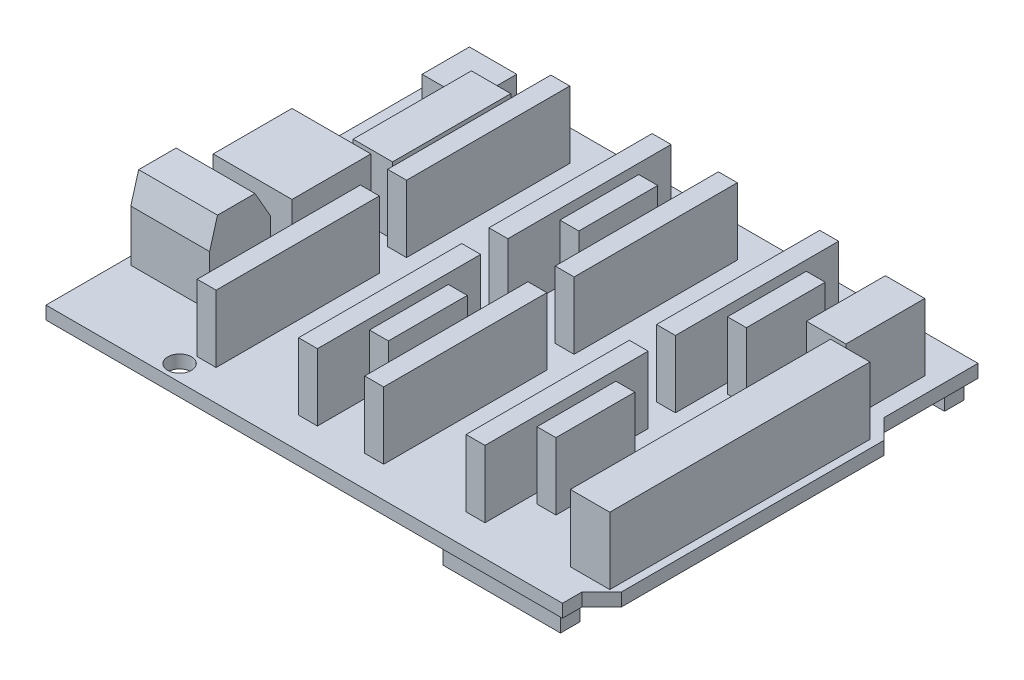
from build123d import *

# Parameters (mm, degrees)
SKETCH1_R           = 1.5
BOSS_EXTRUDE1_DEPTH = 1.65
SKETCH2_W           = 14.9
SKETCH2_H           = 2.5
SKETCH2_W_2         = 4.5
SKETCH2_W_3         = 9.5
BOSS_EXTRUDE2_DEPTH = 2.5
SKETCH3_W           = 5
SKETCH3_H           = 15
SKETCH3_W_2         = 10
SKETCH3_H_2         = 10
SKETCH3_W_3         = 2.4
SKETCH3_H_3         = 20.7
SKETCH3_H_4         = 33
BOSS_EXTRUDE3_DEPTH = 8.5
SKETCH4_W           = 10
SKETCH4_H           = 7.75
BOSS_EXTRUDE4_DEPTH = 10
CUT_EXTRUDE1_DEPTH  = 10
SKETCH6_W           = 6
SKETCH6_H           = 6
BOSS_EXTRUDE5_DEPTH = 3.5


with BuildPart() as part:
    # Sketch1 → Boss-Extrude1 (new body)
    with BuildSketch(Plane(origin=(0, 0, 0), x_dir=(1, 0, 0), z_dir=(0, 1, 0))):
        Polygon((68, 5), (65.5, 2.5), (65.5, 0), (0, 0), (0, 52.7), (65.5, 52.7), (65.5, 40.75), (68, 38.25), align=None)
        with Locations((13.75, 50.4)):
            Circle(SKETCH1_R, mode=Mode.SUBTRACT)
        with Locations((14.9, 2.04)):
            Circle(SKETCH1_R, mode=Mode.SUBTRACT)
    extrude(amount=BOSS_EXTRUDE1_DEPTH)

    # Sketch2 → Boss-Extrude2 (add)
    with BuildSketch(Plane(origin=(0, 0, 0), x_dir=(-1, 0, 0), z_dir=(0, -1, 0))):
        with Locations((-57.05, 2)):
            Rectangle(SKETCH2_W, SKETCH2_H)
        with Locations((-62.25, 50.7)):
            Rectangle(SKETCH2_W_2, SKETCH2_H)
        with Locations((-27.25, 50.7)):
            Rectangle(SKETCH2_W_3, SKETCH2_H)
    extrude(amount=BOSS_EXTRUDE2_DEPTH)

    # Sketch3 → Boss-Extrude3 (add)
    with BuildSketch(Plane(origin=(0, 1.65, 0), x_dir=(1, 0, 0), z_dir=(0, 1, 0))):
        with Locations((12.25, 36.7)):
            Rectangle(SKETCH3_W, SKETCH3_H)
        with Locations((7.5, 23.7)):
            Rectangle(SKETCH3_W_2, SKETCH3_H_2)
        with Locations((16.45, 14.275)):
            Rectangle(SKETCH3_W_3, SKETCH3_H_3)
        with Locations((29.3, 14.275)):
            Rectangle(SKETCH3_W_3, SKETCH3_H_3)
        with Locations((37.7, 14.275)):
            Rectangle(SKETCH3_W_3, SKETCH3_H_3)
        with Locations((50.55, 14.275)):
            Rectangle(SKETCH3_W_3, SKETCH3_H_3)
        with Locations((16.45, 38.425)):
            Rectangle(SKETCH3_W_3, SKETCH3_H_3)
        with Locations((29.3, 38.425)):
            Rectangle(SKETCH3_W_3, SKETCH3_H_3)
        with Locations((37.7, 38.425)):
            Rectangle(SKETCH3_W_3, SKETCH3_H_3)
        with Locations((50.55, 38.425)):
            Rectangle(SKETCH3_W_3, SKETCH3_H_3)
        with Locations((61, 42.95)):
            Rectangle(SKETCH3_W, SKETCH3_H_2)
        with Locations((64.5, 21)):
            Rectangle(SKETCH3_W, SKETCH3_H_4)
        with Locations((32.95, 14.275)):
            Rectangle(SKETCH3_W_3, SKETCH3_H_2)
        with Locations((32.95, 38.425)):
            Rectangle(SKETCH3_W_3, SKETCH3_H_2)
        with Locations((54.2, 38.425)):
            Rectangle(SKETCH3_W_3, SKETCH3_H_2)
        with Locations((54.2, 14.275)):
            Rectangle(SKETCH3_W_3, SKETCH3_H_2)
    extrude(amount=BOSS_EXTRUDE3_DEPTH)

    # Sketch4 → Boss-Extrude4 (add)
    with BuildSketch(Plane(origin=(0, 1.65, 0), x_dir=(1, 0, 0), z_dir=(0, 1, 0))):
        with Locations((6, 13.625)):
            Rectangle(SKETCH4_W, SKETCH4_H)
    extrude(amount=BOSS_EXTRUDE4_DEPTH)

    # Sketch5 → Cut-Extrude1 (cut)
    with BuildSketch(Plane.ZY.offset(-1)):
        Polygon((-17.5, 8.15), (-15.5, 11.65), (-17.5, 11.65), align=None)
        Polygon((-9.75, 11.65), (-9.75, 8.15), (-10.75, 11.65), align=None)
    extrude(amount=-CUT_EXTRUDE1_DEPTH, mode=Mode.SUBTRACT)

    # Sketch6 → Boss-Extrude5 (add)
    with BuildSketch(Plane(origin=(0, 1.65, 0), x_dir=(1, 0, 0), z_dir=(0, 1, 0))):
        with Locations((5, 48.7)):
            Rectangle(SKETCH6_W, SKETCH6_H)
    extrude(amount=BOSS_EXTRUDE5_DEPTH)


solid = part.part
